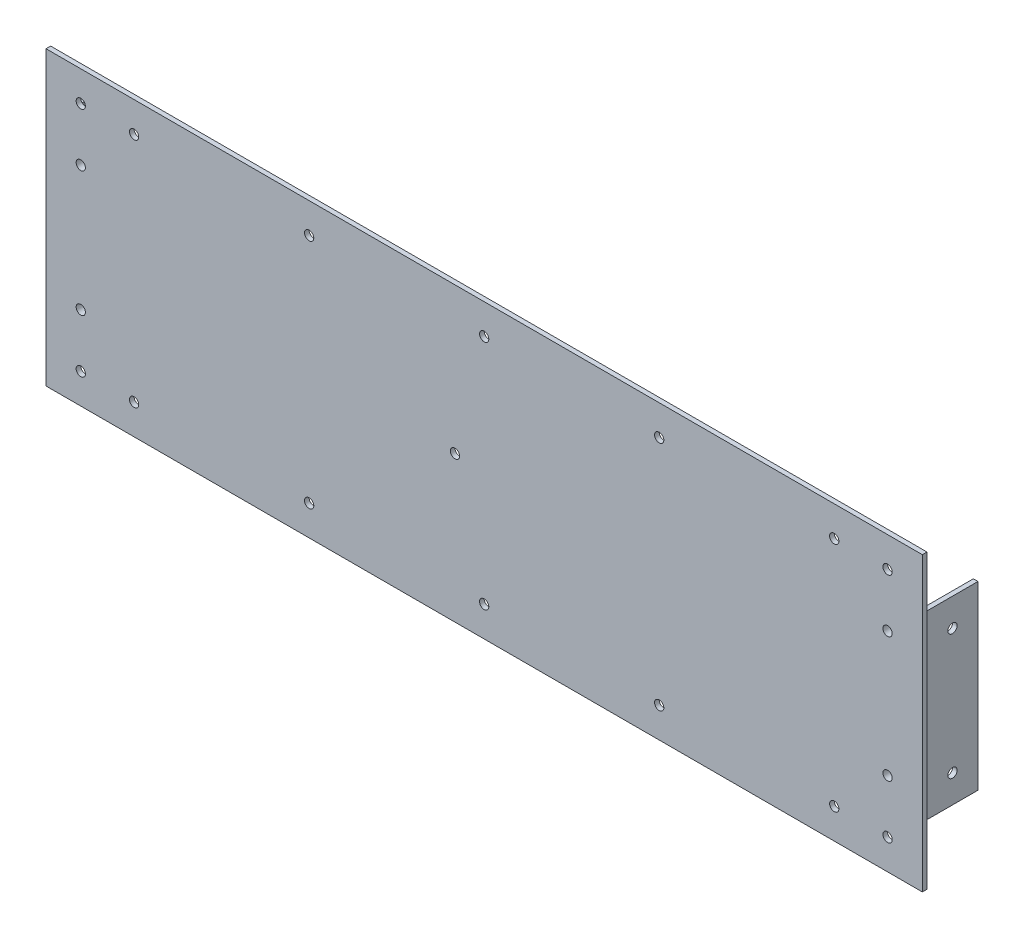
from build123d import *

# Parameters (mm, degrees)
ESQUISSE1_W                  = 300
ESQUISSE1_H                  = 100
BOSS_EXTRU_1_DEPTH           = 1.5875
ESQUISSE2_W                  = 19.05
ESQUISSE2_H                  = 61.9
BOSS_EXTRU_2_DEPTH           = 1.5875
ESQUISSE3_W                  = 1.5875
ESQUISSE3_H                  = 61.9
BOSS_EXTRU_3_DEPTH           = 17.4625
ENL_V_MAT_EXTRU_1_REACH      = 5.175
ESQUISSE4_R                  = 1.5875
ENL_V_MAT_EXTRU_2_REACH      = 22.637
ESQUISSE5_R                  = 1.5875
ENL_V_MAT_EXTRU_3_REACH      = 22.637
ESQUISSE6_R                  = 1.5875
ESQUISSE7_R                  = 1.5875
ENL_V_MAT_EXTRU_4_DEPTH      = 297.825
ENL_V_MAT_EXTRU_4_DEPTH_BACK = 4.175


with BuildPart() as part:
    # Esquisse1 → Boss.-Extru.1 (new body)
    with BuildSketch(Plane.XY):
        with Locations((29.89832913, 31.147540984)):
            Rectangle(ESQUISSE1_W, ESQUISSE1_H)
    extrude(amount=BOSS_EXTRU_1_DEPTH)

    # Esquisse2 → Boss.-Extru.2 (add)
    with BuildSketch(Plane(origin=(0, 0, 0), x_dir=(-1, 0, 0), z_dir=(0, 0, -1))):
        with Locations((108.98917087, 31.147540984)):
            Rectangle(ESQUISSE2_W, ESQUISSE2_H)
        with Locations((-168.78582913, 31.147540984)):
            Rectangle(ESQUISSE2_W, ESQUISSE2_H)
    extrude(amount=BOSS_EXTRU_2_DEPTH)

    # Esquisse3 → Boss.-Extru.3 (add)
    with BuildSketch(Plane(origin=(0, 0, -1.5875), x_dir=(-1, 0, 0), z_dir=(0, 0, -1))):
        with Locations((-177.51707913, 31.147540984)):
            Rectangle(ESQUISSE3_W, ESQUISSE3_H)
        with Locations((117.72042087, 31.147540984)):
            Rectangle(ESQUISSE3_W, ESQUISSE3_H)
    extrude(amount=BOSS_EXTRU_3_DEPTH)

    # Esquisse4 → Enlèv. mat.-Extru.1 (cut, up to next)
    with BuildSketch(Plane(origin=(0, 0, -1.5875), x_dir=(-1, 0, 0), z_dir=(0, 0, -1)), mode=Mode.PRIVATE) as enl_v_mat_extru_1_sk1:
        with Locations((-167.99207913, 52.572540984)):
            Circle(ESQUISSE4_R)
    enl_v_mat_extru_1_tool1 = extrude(enl_v_mat_extru_1_sk1.sketch, amount=-ENL_V_MAT_EXTRU_1_REACH, mode=Mode.PRIVATE) & part.part
    add(enl_v_mat_extru_1_tool1.solids().sort_by_distance((167.992079, 52.572541, -1.5875))[0], mode=Mode.SUBTRACT)
    # Esquisse4 → Enlèv. mat.-Extru.1 (cut, up to next)
    with BuildSketch(Plane(origin=(0, 0, -1.5875), x_dir=(-1, 0, 0), z_dir=(0, 0, -1)), mode=Mode.PRIVATE) as enl_v_mat_extru_1_sk2:
        with Locations((-167.99207913, 9.722540984)):
            Circle(ESQUISSE4_R)
    enl_v_mat_extru_1_tool2 = extrude(enl_v_mat_extru_1_sk2.sketch, amount=-ENL_V_MAT_EXTRU_1_REACH, mode=Mode.PRIVATE) & part.part
    add(enl_v_mat_extru_1_tool2.solids().sort_by_distance((167.992079, 9.722541, -1.5875))[0], mode=Mode.SUBTRACT)
    # Esquisse4 → Enlèv. mat.-Extru.1 (cut, up to next)
    with BuildSketch(Plane(origin=(0, 0, -1.5875), x_dir=(-1, 0, 0), z_dir=(0, 0, -1)), mode=Mode.PRIVATE) as enl_v_mat_extru_1_sk3:
        with Locations((108.19542087, 52.572540984)):
            Circle(ESQUISSE4_R)
    enl_v_mat_extru_1_tool3 = extrude(enl_v_mat_extru_1_sk3.sketch, amount=-ENL_V_MAT_EXTRU_1_REACH, mode=Mode.PRIVATE) & part.part
    add(enl_v_mat_extru_1_tool3.solids().sort_by_distance((-108.195421, 52.572541, -1.5875))[0], mode=Mode.SUBTRACT)
    # Esquisse4 → Enlèv. mat.-Extru.1 (cut, up to next)
    with BuildSketch(Plane(origin=(0, 0, -1.5875), x_dir=(-1, 0, 0), z_dir=(0, 0, -1)), mode=Mode.PRIVATE) as enl_v_mat_extru_1_sk4:
        with Locations((108.19542087, 9.722540984)):
            Circle(ESQUISSE4_R)
    enl_v_mat_extru_1_tool4 = extrude(enl_v_mat_extru_1_sk4.sketch, amount=-ENL_V_MAT_EXTRU_1_REACH, mode=Mode.PRIVATE) & part.part
    add(enl_v_mat_extru_1_tool4.solids().sort_by_distance((-108.195421, 9.722541, -1.5875))[0], mode=Mode.SUBTRACT)

    # Esquisse5 → Enlèv. mat.-Extru.2 (cut, up to next)
    with BuildSketch(Plane.XY.offset(1.5875), mode=Mode.PRIVATE) as enl_v_mat_extru_2_sk1:
        with Locations((-108.19542087, -8.533709016)):
            Circle(ESQUISSE5_R)
    enl_v_mat_extru_2_tool1 = extrude(enl_v_mat_extru_2_sk1.sketch, amount=-ENL_V_MAT_EXTRU_2_REACH, mode=Mode.PRIVATE) & part.part
    add(enl_v_mat_extru_2_tool1.solids().sort_by_distance((-108.195421, -8.533709, 1.5875))[0], mode=Mode.SUBTRACT)
    # Esquisse5 → Enlèv. mat.-Extru.2 (cut, up to next)
    with BuildSketch(Plane.XY.offset(1.5875), mode=Mode.PRIVATE) as enl_v_mat_extru_2_sk2:
        with Locations((-89.93917087, -8.533709016)):
            Circle(ESQUISSE5_R)
    enl_v_mat_extru_2_tool2 = extrude(enl_v_mat_extru_2_sk2.sketch, amount=-ENL_V_MAT_EXTRU_2_REACH, mode=Mode.PRIVATE) & part.part
    add(enl_v_mat_extru_2_tool2.solids().sort_by_distance((-89.939171, -8.533709, 1.5875))[0], mode=Mode.SUBTRACT)
    # Esquisse5 → Enlèv. mat.-Extru.2 (cut, up to next)
    with BuildSketch(Plane.XY.offset(1.5875), mode=Mode.PRIVATE) as enl_v_mat_extru_2_sk3:
        with Locations((-30.02042087, -8.533709016)):
            Circle(ESQUISSE5_R)
    enl_v_mat_extru_2_tool3 = extrude(enl_v_mat_extru_2_sk3.sketch, amount=-ENL_V_MAT_EXTRU_2_REACH, mode=Mode.PRIVATE) & part.part
    add(enl_v_mat_extru_2_tool3.solids().sort_by_distance((-30.020421, -8.533709, 1.5875))[0], mode=Mode.SUBTRACT)
    # Esquisse5 → Enlèv. mat.-Extru.2 (cut, up to next)
    with BuildSketch(Plane.XY.offset(1.5875), mode=Mode.PRIVATE) as enl_v_mat_extru_2_sk4:
        with Locations((29.89832913, -8.533709016)):
            Circle(ESQUISSE5_R)
    enl_v_mat_extru_2_tool4 = extrude(enl_v_mat_extru_2_sk4.sketch, amount=-ENL_V_MAT_EXTRU_2_REACH, mode=Mode.PRIVATE) & part.part
    add(enl_v_mat_extru_2_tool4.solids().sort_by_distance((29.898329, -8.533709, 1.5875))[0], mode=Mode.SUBTRACT)
    # Esquisse5 → Enlèv. mat.-Extru.2 (cut, up to next)
    with BuildSketch(Plane.XY.offset(1.5875), mode=Mode.PRIVATE) as enl_v_mat_extru_2_sk5:
        with Locations((89.81707913, -8.533709016)):
            Circle(ESQUISSE5_R)
    enl_v_mat_extru_2_tool5 = extrude(enl_v_mat_extru_2_sk5.sketch, amount=-ENL_V_MAT_EXTRU_2_REACH, mode=Mode.PRIVATE) & part.part
    add(enl_v_mat_extru_2_tool5.solids().sort_by_distance((89.817079, -8.533709, 1.5875))[0], mode=Mode.SUBTRACT)
    # Esquisse5 → Enlèv. mat.-Extru.2 (cut, up to next)
    with BuildSketch(Plane.XY.offset(1.5875), mode=Mode.PRIVATE) as enl_v_mat_extru_2_sk6:
        with Locations((149.73582913, -8.533709016)):
            Circle(ESQUISSE5_R)
    enl_v_mat_extru_2_tool6 = extrude(enl_v_mat_extru_2_sk6.sketch, amount=-ENL_V_MAT_EXTRU_2_REACH, mode=Mode.PRIVATE) & part.part
    add(enl_v_mat_extru_2_tool6.solids().sort_by_distance((149.735829, -8.533709, 1.5875))[0], mode=Mode.SUBTRACT)
    # Esquisse5 → Enlèv. mat.-Extru.2 (cut, up to next)
    with BuildSketch(Plane.XY.offset(1.5875), mode=Mode.PRIVATE) as enl_v_mat_extru_2_sk7:
        with Locations((167.99207913, -8.533709016)):
            Circle(ESQUISSE5_R)
    enl_v_mat_extru_2_tool7 = extrude(enl_v_mat_extru_2_sk7.sketch, amount=-ENL_V_MAT_EXTRU_2_REACH, mode=Mode.PRIVATE) & part.part
    add(enl_v_mat_extru_2_tool7.solids().sort_by_distance((167.992079, -8.533709, 1.5875))[0], mode=Mode.SUBTRACT)
    # Esquisse5 → Enlèv. mat.-Extru.2 (cut, up to next)
    with BuildSketch(Plane.XY.offset(1.5875), mode=Mode.PRIVATE) as enl_v_mat_extru_2_sk8:
        with Locations((167.99207913, 70.828790984)):
            Circle(ESQUISSE5_R)
    enl_v_mat_extru_2_tool8 = extrude(enl_v_mat_extru_2_sk8.sketch, amount=-ENL_V_MAT_EXTRU_2_REACH, mode=Mode.PRIVATE) & part.part
    add(enl_v_mat_extru_2_tool8.solids().sort_by_distance((167.992079, 70.828791, 1.5875))[0], mode=Mode.SUBTRACT)
    # Esquisse5 → Enlèv. mat.-Extru.2 (cut, up to next)
    with BuildSketch(Plane.XY.offset(1.5875), mode=Mode.PRIVATE) as enl_v_mat_extru_2_sk9:
        with Locations((149.73582913, 70.828790984)):
            Circle(ESQUISSE5_R)
    enl_v_mat_extru_2_tool9 = extrude(enl_v_mat_extru_2_sk9.sketch, amount=-ENL_V_MAT_EXTRU_2_REACH, mode=Mode.PRIVATE) & part.part
    add(enl_v_mat_extru_2_tool9.solids().sort_by_distance((149.735829, 70.828791, 1.5875))[0], mode=Mode.SUBTRACT)
    # Esquisse5 → Enlèv. mat.-Extru.2 (cut, up to next)
    with BuildSketch(Plane.XY.offset(1.5875), mode=Mode.PRIVATE) as enl_v_mat_extru_2_sk10:
        with Locations((89.81707913, 70.828790984)):
            Circle(ESQUISSE5_R)
    enl_v_mat_extru_2_tool10 = extrude(enl_v_mat_extru_2_sk10.sketch, amount=-ENL_V_MAT_EXTRU_2_REACH, mode=Mode.PRIVATE) & part.part
    add(enl_v_mat_extru_2_tool10.solids().sort_by_distance((89.817079, 70.828791, 1.5875))[0], mode=Mode.SUBTRACT)
    # Esquisse5 → Enlèv. mat.-Extru.2 (cut, up to next)
    with BuildSketch(Plane.XY.offset(1.5875), mode=Mode.PRIVATE) as enl_v_mat_extru_2_sk11:
        with Locations((29.89832913, 70.828790984)):
            Circle(ESQUISSE5_R)
    enl_v_mat_extru_2_tool11 = extrude(enl_v_mat_extru_2_sk11.sketch, amount=-ENL_V_MAT_EXTRU_2_REACH, mode=Mode.PRIVATE) & part.part
    add(enl_v_mat_extru_2_tool11.solids().sort_by_distance((29.898329, 70.828791, 1.5875))[0], mode=Mode.SUBTRACT)
    # Esquisse5 → Enlèv. mat.-Extru.2 (cut, up to next)
    with BuildSketch(Plane.XY.offset(1.5875), mode=Mode.PRIVATE) as enl_v_mat_extru_2_sk12:
        with Locations((-30.02042087, 70.828790984)):
            Circle(ESQUISSE5_R)
    enl_v_mat_extru_2_tool12 = extrude(enl_v_mat_extru_2_sk12.sketch, amount=-ENL_V_MAT_EXTRU_2_REACH, mode=Mode.PRIVATE) & part.part
    add(enl_v_mat_extru_2_tool12.solids().sort_by_distance((-30.020421, 70.828791, 1.5875))[0], mode=Mode.SUBTRACT)
    # Esquisse5 → Enlèv. mat.-Extru.2 (cut, up to next)
    with BuildSketch(Plane.XY.offset(1.5875), mode=Mode.PRIVATE) as enl_v_mat_extru_2_sk13:
        with Locations((-89.93917087, 70.828790984)):
            Circle(ESQUISSE5_R)
    enl_v_mat_extru_2_tool13 = extrude(enl_v_mat_extru_2_sk13.sketch, amount=-ENL_V_MAT_EXTRU_2_REACH, mode=Mode.PRIVATE) & part.part
    add(enl_v_mat_extru_2_tool13.solids().sort_by_distance((-89.939171, 70.828791, 1.5875))[0], mode=Mode.SUBTRACT)
    # Esquisse5 → Enlèv. mat.-Extru.2 (cut, up to next)
    with BuildSketch(Plane.XY.offset(1.5875), mode=Mode.PRIVATE) as enl_v_mat_extru_2_sk14:
        with Locations((-108.19542087, 70.828790984)):
            Circle(ESQUISSE5_R)
    enl_v_mat_extru_2_tool14 = extrude(enl_v_mat_extru_2_sk14.sketch, amount=-ENL_V_MAT_EXTRU_2_REACH, mode=Mode.PRIVATE) & part.part
    add(enl_v_mat_extru_2_tool14.solids().sort_by_distance((-108.195421, 70.828791, 1.5875))[0], mode=Mode.SUBTRACT)

    # Esquisse6 → Enlèv. mat.-Extru.3 (cut, up to next)
    with BuildSketch(Plane.XY.offset(1.5875), mode=Mode.PRIVATE) as enl_v_mat_extru_3_sk1:
        with Locations((19.89832913, 31.147540984)):
            Circle(ESQUISSE6_R)
    enl_v_mat_extru_3_tool1 = extrude(enl_v_mat_extru_3_sk1.sketch, amount=-ENL_V_MAT_EXTRU_3_REACH, mode=Mode.PRIVATE) & part.part
    add(enl_v_mat_extru_3_tool1.solids().sort_by_distance((19.898329, 31.147541, 1.5875))[0], mode=Mode.SUBTRACT)

    # Esquisse7 → Enlèv. mat.-Extru.4 (cut, two sides)
    with BuildSketch(Plane.ZY.offset(-176.72332913)) as enl_v_mat_extru_4_sk:
        with Locations((-10.31875, 52.572540984)):
            Circle(ESQUISSE7_R)
        with Locations((-10.31875, 9.722540984)):
            Circle(ESQUISSE7_R)
    extrude(amount=ENL_V_MAT_EXTRU_4_DEPTH, mode=Mode.SUBTRACT)
    extrude(enl_v_mat_extru_4_sk.sketch, amount=-ENL_V_MAT_EXTRU_4_DEPTH_BACK, mode=Mode.SUBTRACT)


solid = part.part
